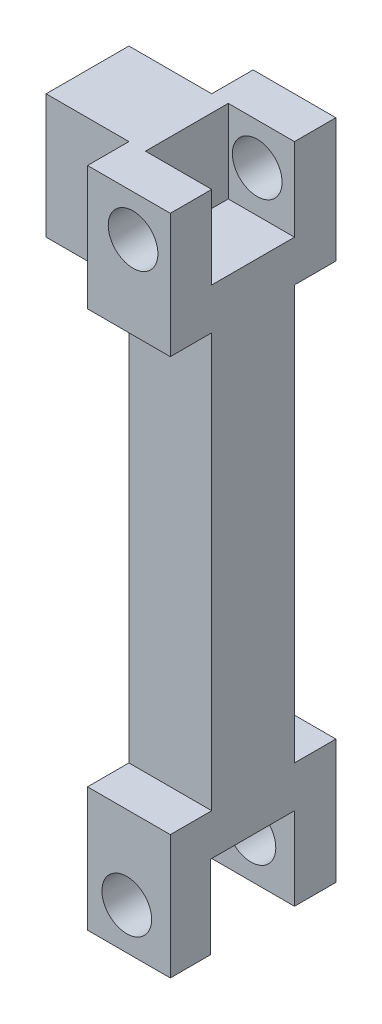
from build123d import *

# Parameters (mm, degrees)
BASE_EXTRUDE_DEPTH  = 25.4
SKETCH7_W           = 12.7
SKETCH7_H           = 38.1
BOSS_EXTRUDE5_DEPTH = 25.4
SKETCH8_W           = 25.751736715
SKETCH8_H           = 25.4
CUT_EXTRUDE5_DEPTH  = 25.4
SKETCH11_W          = 12.7
SKETCH11_H          = 38.1
BOSS_EXTRUDE6_DEPTH = 25.4
SKETCH12_W          = 25.4
SKETCH12_H          = 25.4
CUT_EXTRUDE7_DEPTH  = 20.32
SKETCH13_R          = 7.62
CUT_EXTRUDE8_DEPTH  = 20.32
SKETCH14_R          = 7.62
CUT_EXTRUDE9_DEPTH  = 50.8


with BuildPart() as part:
    # Sketch1 → Base-Extrude (new body)
    with BuildSketch(Plane.XY):
        Polygon((-4.57611336, -135.706612686), (-29.97611336, -135.706612686), (-29.97611336, 29.393387314), (-55.37611336, 29.393387314), (-55.37611336, 67.493387314), (-29.97611336, 67.493387314), (-4.57611336, 67.493387314), align=None)
    extrude(amount=-BASE_EXTRUDE_DEPTH)

    # Sketch7 → Boss-Extrude5 (add)
    with BuildSketch(Plane.ZY.offset(29.97611336)):
        with Locations((-31.75, -116.656612686)):
            Rectangle(SKETCH7_W, SKETCH7_H)
        with Locations((6.35, -116.656612686)):
            Rectangle(SKETCH7_W, SKETCH7_H)
    extrude(amount=-BOSS_EXTRUDE5_DEPTH)

    # Sketch8 → Cut-Extrude5 (cut)
    with BuildSketch(Plane.ZY.offset(29.97611336)):
        with Locations((-12.524131643, -123.006612686)):
            Rectangle(SKETCH8_W, SKETCH8_H)
    extrude(amount=-CUT_EXTRUDE5_DEPTH, mode=Mode.SUBTRACT)

    # Sketch11 → Boss-Extrude6 (add)
    with BuildSketch(Plane(origin=(-4.57611336, 0, 0), x_dir=(0, 0, -1), z_dir=(1, 0, 0))):
        with Locations((31.75, 48.443387314)):
            Rectangle(SKETCH11_W, SKETCH11_H)
        with Locations((-6.35, 48.443387314)):
            Rectangle(SKETCH11_W, SKETCH11_H)
    extrude(amount=-BOSS_EXTRUDE6_DEPTH)

    # Sketch12 → Cut-Extrude7 (cut)
    with BuildSketch(Plane(origin=(-4.57611336, 0, 0), x_dir=(0, 0, -1), z_dir=(1, 0, 0))):
        with Locations((12.7, 54.793387314)):
            Rectangle(SKETCH12_W, SKETCH12_H)
    extrude(amount=-CUT_EXTRUDE7_DEPTH, mode=Mode.SUBTRACT)

    # Sketch13 → Cut-Extrude8 (cut)
    with BuildSketch(Plane.ZY.offset(55.37611336)):
        with Locations(Location((-13.088541232, 49.429752215, 0), (0, 0, 270))):
            Circle(SKETCH13_R)
    extrude(amount=-CUT_EXTRUDE8_DEPTH, mode=Mode.SUBTRACT)

    # Sketch14 → Cut-Extrude9 (cut)
    with BuildSketch(Plane(origin=(0, 0, -38.1), x_dir=(-1, 0, 0), z_dir=(0, 0, -1))):
        with Locations(Location((16.00611336, 54.793387314, 0), (0, 0, 90))):
            Circle(SKETCH14_R)
        with Locations(Location((17.931310165, -123.006612686, 0), (0, 0, 90))):
            Circle(SKETCH14_R)
    extrude(amount=-CUT_EXTRUDE9_DEPTH, mode=Mode.SUBTRACT)


solid = part.part
